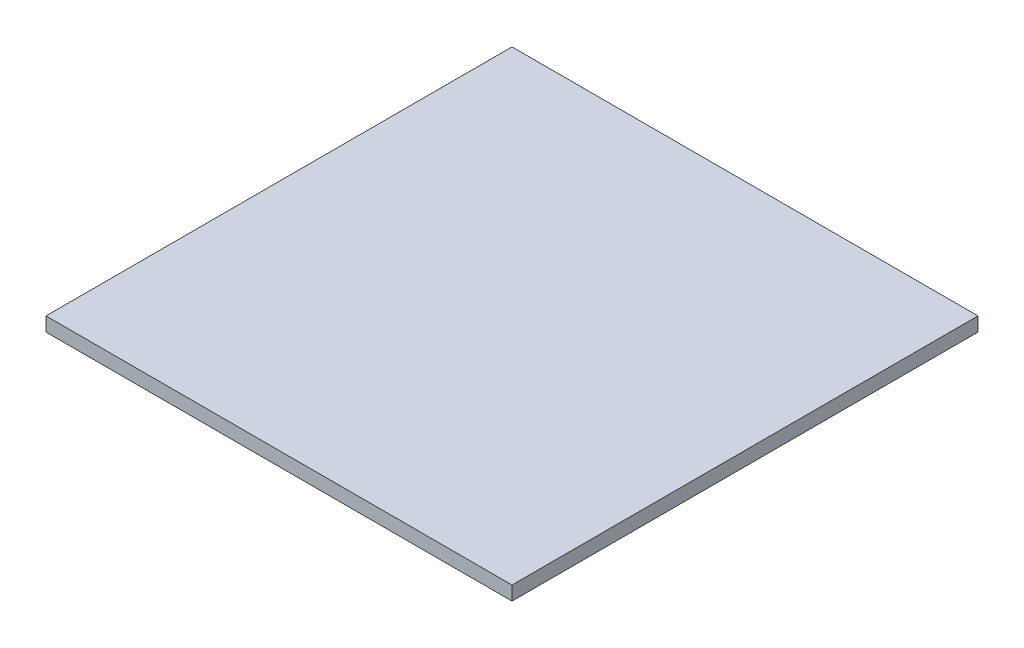
from build123d import *

# Parameters (mm, degrees)
SKETCH1_W           = 100
SKETCH1_H           = 100
BOSS_EXTRUDE1_DEPTH = 3


with BuildPart() as part:
    # Sketch1 → Boss-Extrude1 (new body)
    with BuildSketch(Plane(origin=(0, 0, 0), x_dir=(1, 0, 0), z_dir=(0, 1, 0))):
        Rectangle(SKETCH1_W, SKETCH1_H)
    extrude(amount=BOSS_EXTRUDE1_DEPTH)


solid = part.part
